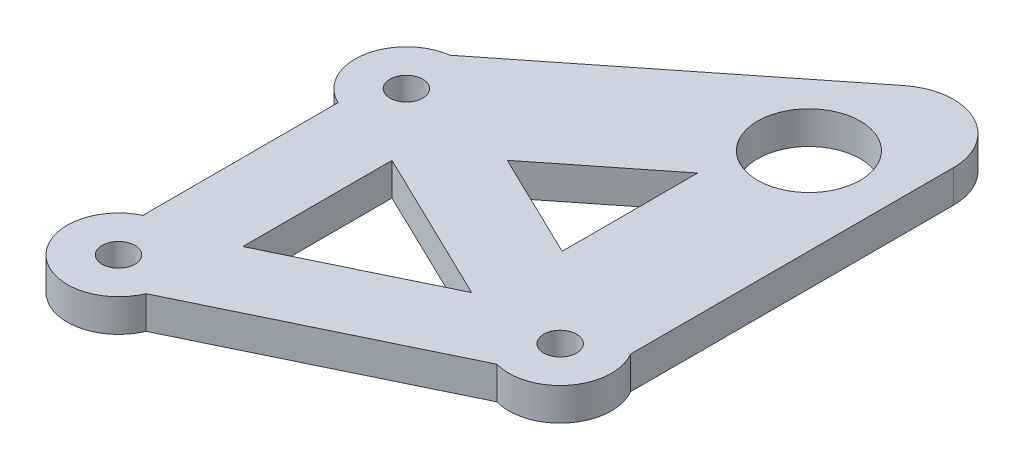
from build123d import *

# Parameters (mm, degrees)
BOSS_EXTRUDE1_DEPTH            = 3.18
F_3_2_3_2_DIAMETER_HOLE1_D     = 3.2
F_3_2_3_2_DIAMETER_HOLE1_DEPTH = 3.18
F_10_0_10_DIAMETER_HOLE1_D     = 10
F_10_0_10_DIAMETER_HOLE1_DEPTH = 3.18


with BuildPart() as part:
    # Sketch1 → Boss-Extrude1 (new body)
    with BuildSketch(Plane(origin=(0, 0, 0), x_dir=(1, 0, 0), z_dir=(0, 1, 0))):
        with BuildLine():
            Line((-16.648706397, -9.505239672), (-16.648706397, 9.505239672))
            ThreePointArc((-16.648706397, 9.505239672), (-19.441368429, 14.783464504), (-15.185935574, 18.972725753))
            Line((-15.185935574, 18.972725753), (9.48849845, 38.527527259))
            ThreePointArc((9.48849845, 38.527527259), (15.561102251, 39.197729336), (18.807607076, 34.022220261))
            Line((18.807607076, 34.022220261), (18.807607076, 2.538606169))
            ThreePointArc((18.807607076, 2.538606169), (18.464212779, -3.047132594), (13.154706871, -4.815619005))
            Line((13.154706871, -4.815619005), (-9.89031278, -15.956694023))
            ThreePointArc((-9.89031278, -15.956694023), (-17.95245166, -17.636708108), (-16.648706397, -9.505239672))
        make_face()
        Polygon((-9.148706397, 7.267686973), (5.884312306, 0), (-9.148706397, -7.267686973), align=None, mode=Mode.SUBTRACT)
        Polygon((-3.543212985, 12.88819957), (6.807607076, 7.884113458), (6.807607076, 21.091355578), align=None, mode=Mode.SUBTRACT)
    extrude(amount=BOSS_EXTRUDE1_DEPTH)

    # Ø3.2 (3.2) Diameter Hole1
    with Locations(Plane(origin=(0, 3.18, 0), x_dir=(-1, 0, 0), z_dir=(0, 1, 0))):
        with Locations((-14.5, 0), (14.5, 14.02), (14.5, -14.02)):
            Hole(F_3_2_3_2_DIAMETER_HOLE1_D / 2, depth=F_3_2_3_2_DIAMETER_HOLE1_DEPTH)

    # Ø10.0 (10) Diameter Hole1
    with Locations(Plane(origin=(0, 0, 0), x_dir=(-1, 0, 0), z_dir=(0, -1, 0))):
        with Locations((-10.338071706, 28.394028492)):
            Hole(F_10_0_10_DIAMETER_HOLE1_D / 2, depth=F_10_0_10_DIAMETER_HOLE1_DEPTH)


solid = part.part
